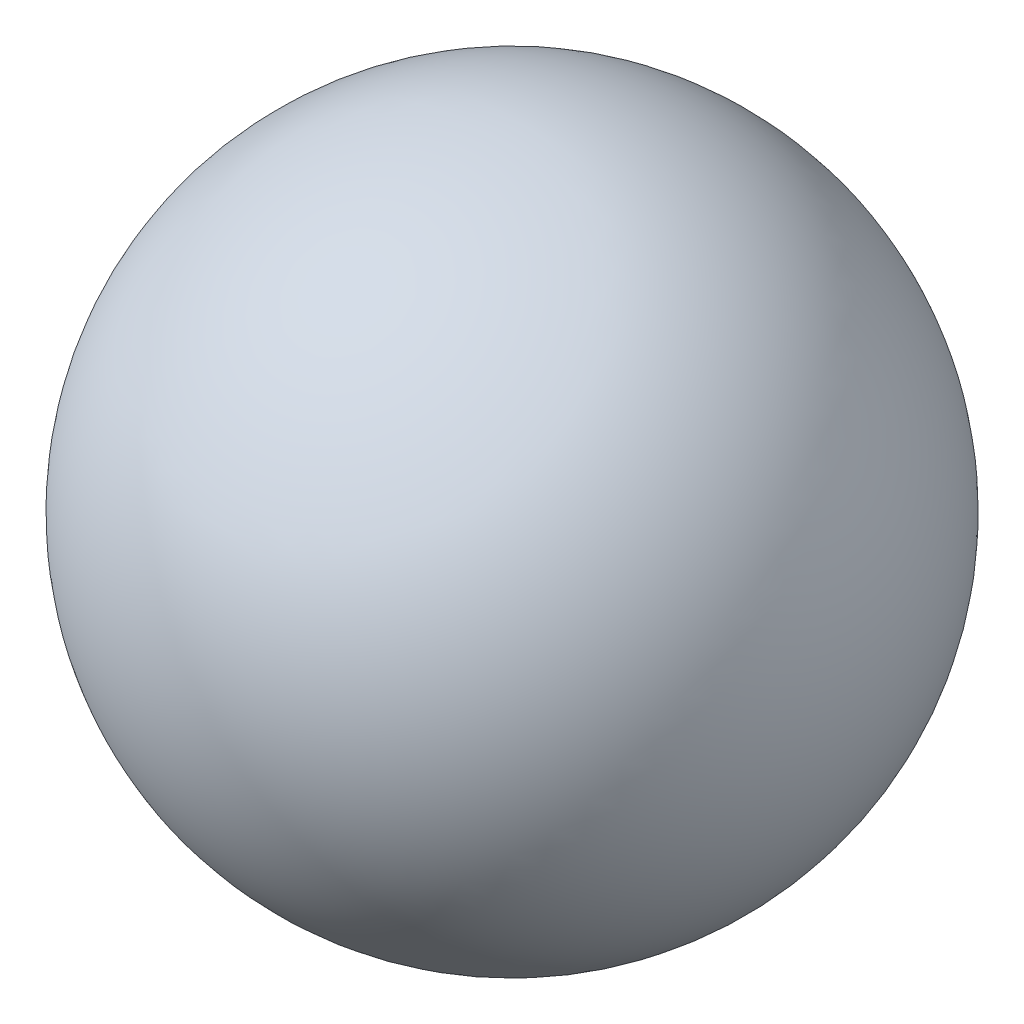
from build123d import *


with BuildPart() as part:
    # Sketch1 → Revolve1 (revolve)
    with BuildSketch(Plane(origin=(0, 0, 0), x_dir=(1, 0, 0), z_dir=(0, 1, 0))):
        with BuildLine():
            Line((0, 0), (0, 40))
            ThreePointArc((0, 40), (-20, 20), (0, 0))
        make_face()
    revolve(axis=Axis((0, 0, 0), (0, 0, -1)))


solid = part.part
